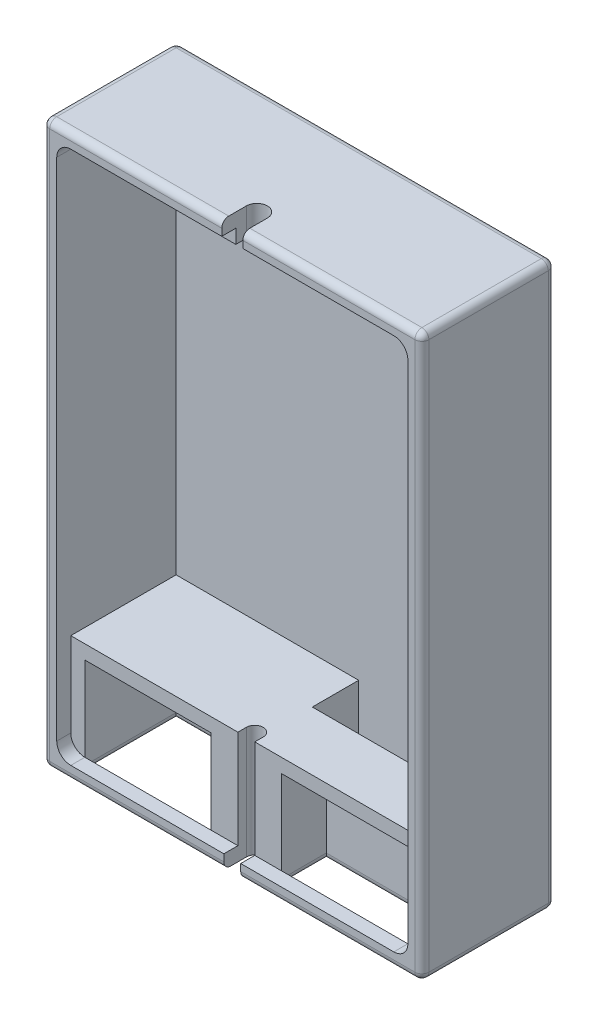
from build123d import *

# Parameters (mm, degrees)
SKETCH_2_W           = 27
SKETCH_2_H           = 40
EXTRUDE_1_DEPTH      = 10
CUT_EXTRUDE_1_DEPTH  = 1.5
CUT_EXTRUDE_2_DEPTH  = 7.5
SKETCH_9_W           = 9
SKETCH_9_H           = 4.718038217
CUT_EXTRUDE_8_DEPTH  = 3.2
SKETCH_9_3_W         = 9
SKETCH_9_3_H         = 4.718038217
CUT_EXTRUDE_9_DEPTH  = 6.5
SKETCH_12_W          = 12
SKETCH_12_H          = 3.3
CUT_EXTRUDE_10_DEPTH = 7
SKETCH_13_W          = 9
SKETCH_13_H          = 6.5
SKETCH_13_H_2        = 3.2
CUT_EXTRUDE_11_DEPTH = 3.281961783
CUT_EXTRUDE_12_REACH = 42
SKETCH_14_W          = 1.2
SKETCH_14_H          = 2.1
SKETCH_16_2_W        = 7
SKETCH_16_2_H        = 2.5
EXTRUDE_3_DEPTH      = 1
SKETCH_16_W          = 7
SKETCH_16_H          = 2.5
EXTRUDE_2_DEPTH      = 1
CUT_EXTRUDE_14_DEPTH = 2
SKETCH_18_W          = 27
SKETCH_18_H          = 40
CUT_EXTRUDE_15_DEPTH = 0.5
FILLET_1_R           = 0.5


with BuildPart() as part:
    # Sketch 2 → Extrude 1 (new body)
    with BuildSketch(Plane.XY):
        with Locations((13.5, 20)):
            Rectangle(SKETCH_2_W, SKETCH_2_H)
    extrude(amount=EXTRUDE_1_DEPTH)

    # Sketch 3 → Cut-Extrude 1 (cut)
    with BuildSketch(Plane.XY.offset(10)):
        with BuildLine():
            Line((1, 38), (1, 2))
            ThreePointArc((1, 2), (1.292893219, 1.292893219), (2, 1))
            Line((2, 1), (25, 1))
            ThreePointArc((25, 1), (25.707106781, 1.292893219), (26, 2))
            Line((26, 2), (26, 38))
            ThreePointArc((26, 38), (25.707106781, 38.707106781), (25, 39))
            Line((25, 39), (2, 39))
            ThreePointArc((2, 39), (1.292893219, 38.707106781), (1, 38))
        make_face()
    extrude(amount=-CUT_EXTRUDE_1_DEPTH, mode=Mode.SUBTRACT)

    # Sketch 5 → Cut-Extrude 2 (cut)
    with BuildSketch(Plane.XY.offset(8.5)):
        with BuildLine():
            Line((2, 39), (25, 39))
            ThreePointArc((25, 39), (25.707106781, 38.707106781), (26, 38))
            Line((26, 38), (26, 8))
            Line((26, 8), (1, 8))
            Line((1, 8), (1, 38))
            ThreePointArc((1, 38), (1.292893219, 38.707106781), (2, 39))
        make_face()
    extrude(amount=-CUT_EXTRUDE_2_DEPTH, mode=Mode.SUBTRACT)

    # Sketch 9 → Cut-Extrude 8 (cut)
    with BuildSketch(Plane.XY.offset(8.5)):
        with Locations((20.5, 4.640980891)):
            Rectangle(SKETCH_9_W, SKETCH_9_H)
    extrude(amount=-CUT_EXTRUDE_8_DEPTH, mode=Mode.SUBTRACT)

    # Sketch 9_3 → Cut-Extrude 9 (cut)
    with BuildSketch(Plane.XY.offset(8.5)):
        with Locations((6.5, 4.640980891)):
            Rectangle(SKETCH_9_3_W, SKETCH_9_3_H)
    extrude(amount=-CUT_EXTRUDE_9_DEPTH, mode=Mode.SUBTRACT)

    # Sketch 12 → Cut-Extrude 10 (cut)
    with BuildSketch(Plane(origin=(0, 8, 0), x_dir=(1, 0, 0), z_dir=(0, 1, 0))):
        with Locations((20, -2.65)):
            Rectangle(SKETCH_12_W, SKETCH_12_H)
    extrude(amount=-CUT_EXTRUDE_10_DEPTH, mode=Mode.SUBTRACT)

    # Sketch 13 → Cut-Extrude 11 (cut, through all)
    with BuildSketch(Plane(origin=(0, 2.281961783, 0), x_dir=(1, 0, 0), z_dir=(0, 1, 0))):
        with Locations((6.5, -5.25)):
            Rectangle(SKETCH_13_W, SKETCH_13_H)
        with Locations((20.5, -6.9)):
            Rectangle(SKETCH_13_W, SKETCH_13_H_2)
    extrude(amount=-CUT_EXTRUDE_11_DEPTH, mode=Mode.SUBTRACT)

    # Sketch 14 → Cut-Extrude 12 (cut, up to next)
    with BuildSketch(Plane.XZ, mode=Mode.PRIVATE) as cut_extrude_12_sk1:
        with BuildLine():
            Line((12.9, 7.9), (14.1, 7.9))
            ThreePointArc((14.1, 7.9), (13.5, 7.3), (12.9, 7.9))
        make_face()
    cut_extrude_12_tool1 = extrude(cut_extrude_12_sk1.sketch, amount=-CUT_EXTRUDE_12_REACH, mode=Mode.PRIVATE) & part.part
    add(cut_extrude_12_tool1.solids().sort_by_distance((13.5, 0, 7.645352))[0], mode=Mode.SUBTRACT)
    # Sketch 14 → Cut-Extrude 12 (cut, up to next)
    with BuildSketch(Plane.XZ, mode=Mode.PRIVATE) as cut_extrude_12_sk2:
        with Locations((13.5, 8.95)):
            Rectangle(SKETCH_14_W, SKETCH_14_H)
    cut_extrude_12_tool2 = extrude(cut_extrude_12_sk2.sketch, amount=-CUT_EXTRUDE_12_REACH, mode=Mode.PRIVATE) & part.part
    add(cut_extrude_12_tool2.solids().sort_by_distance((13.5, 0, 8.95))[0], mode=Mode.SUBTRACT)

    # Sketch 16_2 → Extrude 3 (add)
    with BuildSketch(Plane.XZ.offset(-39)):
        with Locations((13.5, 7.25)):
            Rectangle(SKETCH_16_2_W, SKETCH_16_2_H)
    extrude(amount=EXTRUDE_3_DEPTH)

    # Sketch 16 → Extrude 2 (add)
    with BuildSketch(Plane.XZ.offset(-39)):
        with Locations((13.5, 7.25)):
            Rectangle(SKETCH_16_W, SKETCH_16_H)
    extrude(amount=EXTRUDE_2_DEPTH)

    # Sketch 17 → Cut-Extrude 14 (cut)
    with BuildSketch(Plane(origin=(0, 40, 0), x_dir=(1, 0, 0), z_dir=(0, 1, 0))):
        with BuildLine():
            Line((14.25, -7.75), (14.25, -10))
            Line((14.25, -10), (12.75, -10))
            Line((12.75, -10), (12.75, -7.75))
            ThreePointArc((12.75, -7.75), (13.5, -7), (14.25, -7.75))
        make_face()
    extrude(amount=-CUT_EXTRUDE_14_DEPTH, mode=Mode.SUBTRACT)

    # Sketch 18 → Cut-Extrude 15 (cut)
    with BuildSketch(Plane.XY.offset(10)):
        with Locations((13.5, 20)):
            Rectangle(SKETCH_18_W, SKETCH_18_H)
    extrude(amount=-CUT_EXTRUDE_15_DEPTH, mode=Mode.SUBTRACT)

    # Fillet 1
    fillet_1_edges = [part.edges().sort_by_distance(p)[0] for p in [
        (25, 0, 6.9),
        (16, 0, 6.9),
        (20.5, 0, 5.3),
        (27, 40, 4.75),
        (0, 40, 4.75),
        (27, 0, 4.75),
        (0, 0, 4.75),
        (20.55, 0, 9.5),
        (20.625, 40, 9.5),
        (6.375, 40, 9.5),
        (0, 20, 9.5),
        (27, 20, 9.5),
        (6.45, 0, 9.5),
        (13.5, 40, 0),
        (27, 20, 0),
        (13.5, 0, 0),
        (0, 20, 0),
        (11, 0, 5.25),
        (2, 0, 5.25),
        (6.5, 0, 2),
    ]]
    fillet(fillet_1_edges, radius=FILLET_1_R)


solid = part.part
